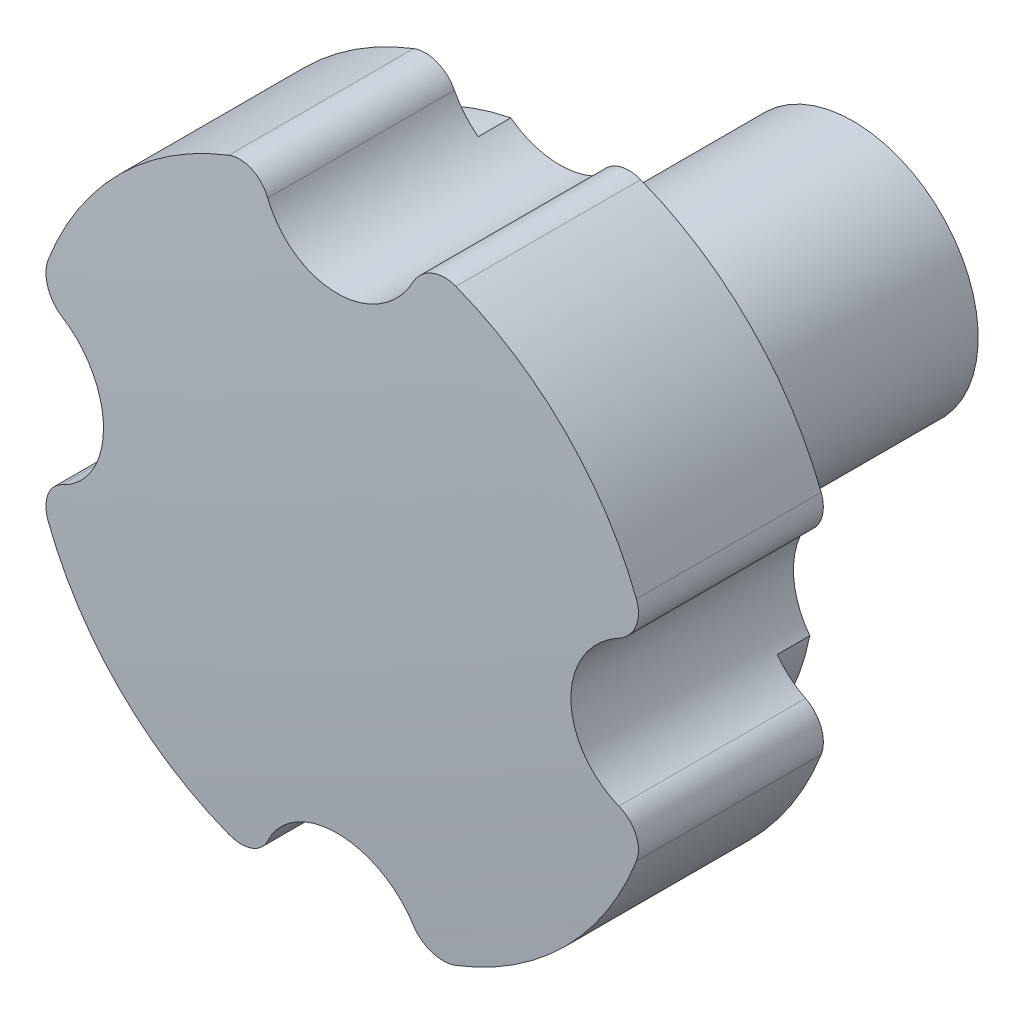
from build123d import *

# Parameters (mm, degrees)
CUT_EXTRUDE1_REACH = 50.053
SKETCH2_R          = 7.5
FILLET1_R          = 3


with BuildPart() as part:
    # Sketch1 → Revolve1 (revolve)
    with BuildSketch(Plane(origin=(0, 0, 0), x_dir=(1, 0, 0), z_dir=(0, 1, 0))):
        with BuildLine():
            Line((0, 18.052635051), (0, 0))
            ThreePointArc((0, 0), (-14.509548929, 0.263245385), (-29, 1.052635051))
            Line((-29, 1.052635051), (-29, 18.052635051))
            Line((-29, 18.052635051), (-23.44, 18.052635051))
            Line((-23.44, 18.052635051), (-23.44, 21.052635051))
            Line((-23.44, 21.052635051), (-11.5, 21.052635051))
            Line((-11.5, 21.052635051), (-11.5, 48.052635051))
            Line((-11.5, 48.052635051), (-6, 48.052635051))
            Line((-6, 48.052635051), (-6, 18.052635051))
            Line((-6, 18.052635051), (0, 18.052635051))
        make_face()
    revolve(axis=Axis((0, 0, -358.843484937), (0, 0, 1)))

    # Sketch2 → Cut-Extrude1 (cut, up to next)
    with BuildSketch(Plane.XY, mode=Mode.PRIVATE) as cut_extrude1_sk1:
        with Locations((0, 29)):
            Circle(SKETCH2_R)
    cut_extrude1_tool1 = extrude(cut_extrude1_sk1.sketch, amount=-CUT_EXTRUDE1_REACH, mode=Mode.PRIVATE) & part.part
    add(cut_extrude1_tool1.solids().sort_by_distance((0, 29, 0))[0], mode=Mode.SUBTRACT)
    # Sketch2 → Cut-Extrude1 (cut, up to next)
    with BuildSketch(Plane.XY, mode=Mode.PRIVATE) as cut_extrude1_sk2:
        with Locations((29, 0)):
            Circle(SKETCH2_R)
    cut_extrude1_tool2 = extrude(cut_extrude1_sk2.sketch, amount=-CUT_EXTRUDE1_REACH, mode=Mode.PRIVATE) & part.part
    add(cut_extrude1_tool2.solids().sort_by_distance((29, 0, 0))[0], mode=Mode.SUBTRACT)
    # Sketch2 → Cut-Extrude1 (cut, up to next)
    with BuildSketch(Plane.XY, mode=Mode.PRIVATE) as cut_extrude1_sk3:
        with Locations((0, -29)):
            Circle(SKETCH2_R)
    cut_extrude1_tool3 = extrude(cut_extrude1_sk3.sketch, amount=-CUT_EXTRUDE1_REACH, mode=Mode.PRIVATE) & part.part
    add(cut_extrude1_tool3.solids().sort_by_distance((0, -29, 0))[0], mode=Mode.SUBTRACT)
    # Sketch2 → Cut-Extrude1 (cut, up to next)
    with BuildSketch(Plane.XY, mode=Mode.PRIVATE) as cut_extrude1_sk4:
        with Locations((-29, 0)):
            Circle(SKETCH2_R)
    cut_extrude1_tool4 = extrude(cut_extrude1_sk4.sketch, amount=-CUT_EXTRUDE1_REACH, mode=Mode.PRIVATE) & part.part
    add(cut_extrude1_tool4.solids().sort_by_distance((-29, 0, 0))[0], mode=Mode.SUBTRACT)

    # Fillet1
    fillet1_edges = [part.edges().sort_by_distance(p)[0] for p in [
        (-28.030172414, -7.437031293, -9.552634751),
        (-28.030172414, 7.437031293, -9.552635051),
        (7.437031293, -28.030172414, -9.552635051),
        (-7.437031293, -28.030172414, -9.552635051),
        (28.030172414, 7.437031293, -9.552635051),
        (28.030172414, -7.437031293, -9.552635051),
        (-7.437031293, 28.030172414, -9.552635051),
        (7.437031293, 28.030172414, -9.552635051),
    ]]
    fillet(fillet1_edges, radius=FILLET1_R)


solid = part.part
